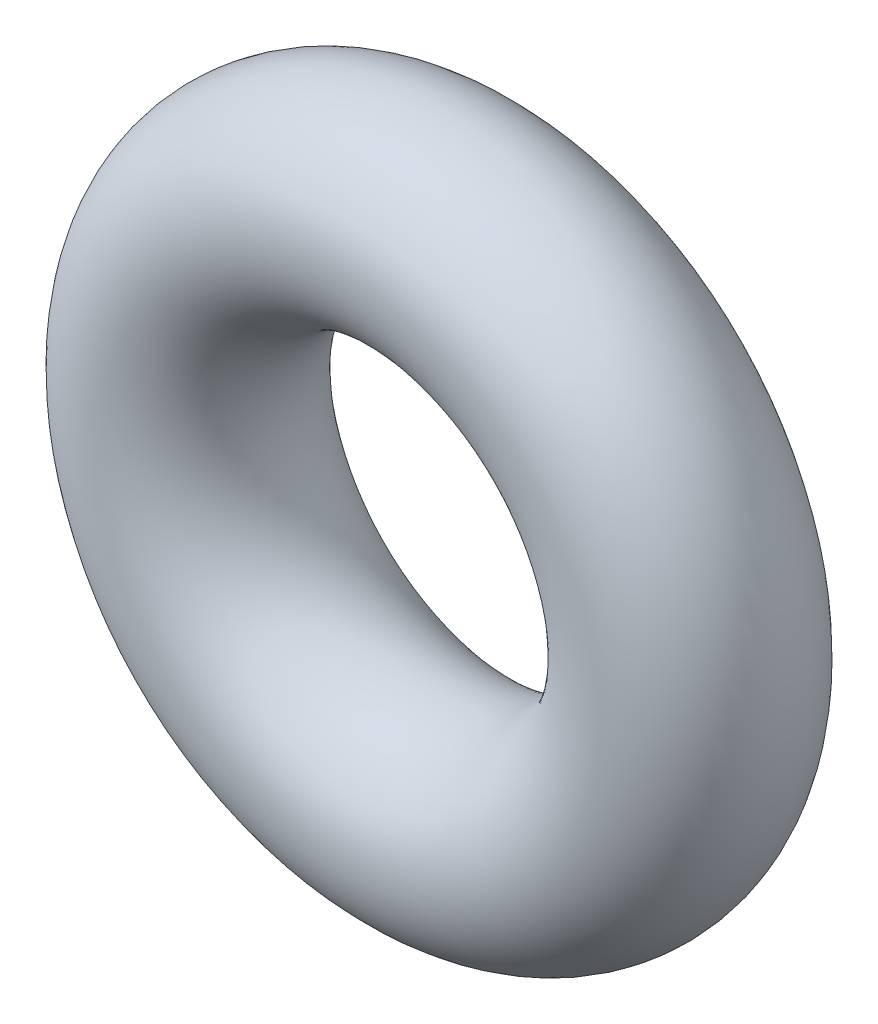
from build123d import *

# Parameters (mm, degrees)
SKETCH1_R = 1


with BuildPart() as part:
    # Sketch1 → Revolve1 (revolve)
    with BuildSketch(Plane(origin=(0, 0, 0), x_dir=(0, -1, 0), z_dir=(1, 0, 0))):
        with Locations((2.5, 0)):
            Circle(SKETCH1_R)
    revolve(axis=Axis((0, 0, 1), (0, 0, -1)))


solid = part.part
